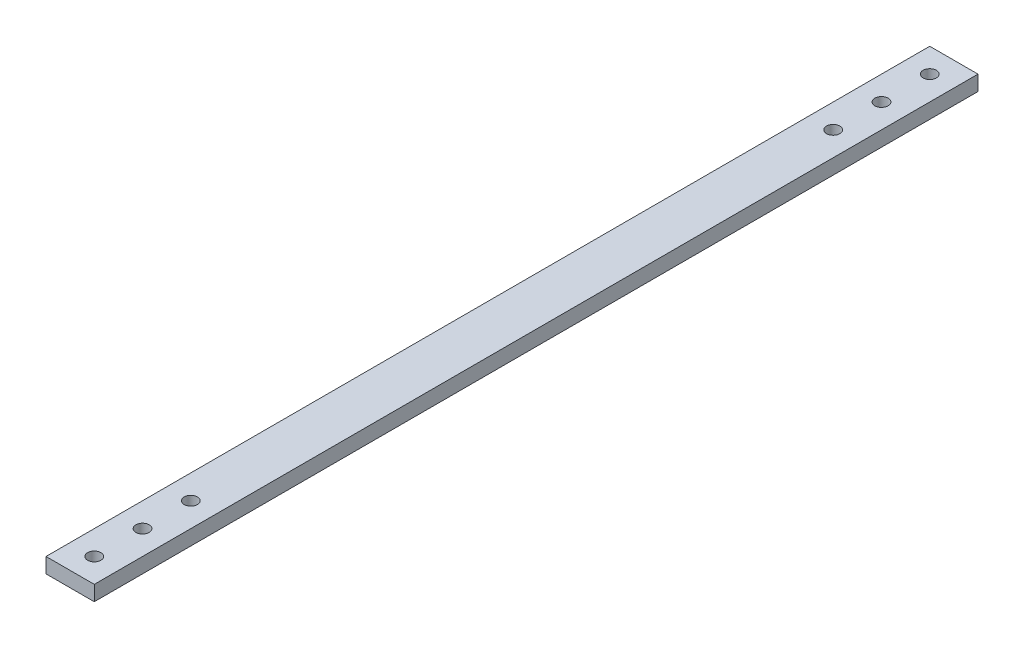
from build123d import *

# Parameters (mm, degrees)
SKETCH3_W           = 25.4
SKETCH3_H           = 7.9375
BOSS_EXTRUDE1_DEPTH = 232.5
SKETCH4_R           = 3.5
CUT_EXTRUDE1_DEPTH  = 8.9375


with BuildPart() as part:
    # Sketch3 → Boss-Extrude1 (new body, symmetric)
    with BuildSketch(Plane.XY):
        Rectangle(SKETCH3_W, SKETCH3_H)
    extrude(amount=BOSS_EXTRUDE1_DEPTH, both=True)

    # Sketch4 → Cut-Extrude1 (cut, through all)
    with BuildSketch(Plane(origin=(0, 3.96875, 0), x_dir=(1, 0, 0), z_dir=(0, 1, 0))):
        with Locations((0, 219.8)):
            Circle(SKETCH4_R)
        with Locations((0, 194.4)):
            Circle(SKETCH4_R)
        with Locations((0, 169)):
            Circle(SKETCH4_R)
        with Locations((0, -169)):
            Circle(SKETCH4_R)
        with Locations((0, -194.4)):
            Circle(SKETCH4_R)
        with Locations((0, -219.8)):
            Circle(SKETCH4_R)
    extrude(amount=-CUT_EXTRUDE1_DEPTH, mode=Mode.SUBTRACT)


solid = part.part
